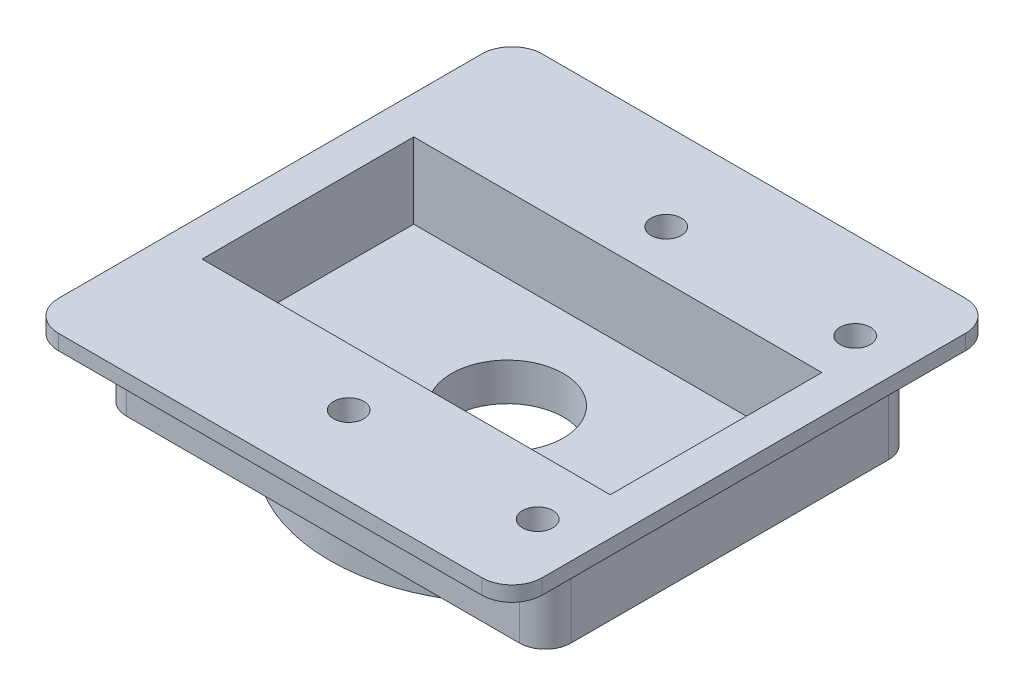
from build123d import *

# Parameters (mm, degrees)
SKETCH_1_W          = 32
SKETCH_1_H          = 32
EXTRUDE_1_DEPTH     = 1
EXTRUDE_2_DEPTH     = 5
SKETCH_2_W          = 27
SKETCH_2_H          = 14
CUT_EXTRUDE_1_DEPTH = 5
SKETCH_4_R          = 11.747624997
EXTRUDE_3_DEPTH     = 2
SKETCH_5_R          = 4.75
CUT_EXTRUDE_2_DEPTH = 0.5
CUT_EXTRUDE_2_TAPER = 37
SKETCH_6_R          = 3.7
CUT_EXTRUDE_3_DEPTH = 8.5
FILLET_1_R          = 2
SKETCH_7_R          = 1
CUT_EXTRUDE_4_DEPTH = 4
CUT_EXTRUDE_4_TAPER = 2


with BuildPart() as part:
    # 草图1 → 凸台-拉伸1 (new body)
    with BuildSketch(Plane(origin=(0, 0, 0), x_dir=(1, 0, 0), z_dir=(0, 1, 0))):
        with Locations((-24.552631543, -18.455578089)):
            Rectangle(SKETCH_1_W, SKETCH_1_H)
    extrude(amount=EXTRUDE_1_DEPTH)

    # 草图3 → 凸台-拉伸2 (add)
    with BuildSketch(Plane.XZ):
        with BuildLine():
            Line((-9.852631543, 8.255578089), (-9.852631543, 29.255578089))
            ThreePointArc((-9.852631543, 29.255578089), (-10.350550015, 30.457659617), (-11.552631543, 30.955578089))
            Line((-11.552631543, 30.955578089), (-37.552631543, 30.955578089))
            ThreePointArc((-37.552631543, 30.955578089), (-38.754713071, 30.457659617), (-39.252631543, 29.255578089))
            Line((-39.252631543, 29.255578089), (-39.252631543, 8.255578089))
            ThreePointArc((-39.252631543, 8.255578089), (-38.754713071, 7.053496561), (-37.552631543, 6.555578089))
            Line((-37.552631543, 6.555578089), (-11.552631543, 6.555578089))
            ThreePointArc((-11.552631543, 6.555578089), (-10.350550015, 7.053496561), (-9.852631543, 8.255578089))
        make_face()
    extrude(amount=EXTRUDE_2_DEPTH)

    # 草图2 → 切除-拉伸1 (cut)
    with BuildSketch(Plane(origin=(0, 1, 0), x_dir=(1, 0, 0), z_dir=(0, 1, 0))):
        with Locations((-24.552631543, -18.455578089)):
            Rectangle(SKETCH_2_W, SKETCH_2_H)
    extrude(amount=-CUT_EXTRUDE_1_DEPTH, mode=Mode.SUBTRACT)

    # 草图4 → 凸台-拉伸3 (add)
    with BuildSketch(Plane.XZ.offset(5)):
        with Locations((-24.552631543, 18.755578089)):
            Circle(SKETCH_4_R)
    extrude(amount=EXTRUDE_3_DEPTH)

    # 草图5 → 切除-拉伸2 (cut)
    with BuildSketch(Plane.XZ.offset(7)):
        with Locations((-24.552631543, 18.755578089)):
            Circle(SKETCH_5_R)
    extrude(amount=-CUT_EXTRUDE_2_DEPTH, taper=CUT_EXTRUDE_2_TAPER, mode=Mode.SUBTRACT)

    # 草图6 → 切除-拉伸3 (cut, through all)
    with BuildSketch(Plane.XZ.offset(6.5)):
        with Locations((-24.552631543, 18.755578089)):
            Circle(SKETCH_6_R)
    extrude(amount=-CUT_EXTRUDE_3_DEPTH, mode=Mode.SUBTRACT)

    # 圆角1
    fillet_1_edges = [part.edges().sort_by_distance(p)[0] for p in [
        (-40.552631543, 0.5, 2.455578089),
        (-8.552631543, 0.5, 2.455578089),
        (-8.552631543, 0.5, 34.455578089),
        (-40.552631543, 0.5, 34.455578089),
    ]]
    fillet(fillet_1_edges, radius=FILLET_1_R)

    # 草图7 → 切除-拉伸4 (cut)
    with BuildSketch(Plane(origin=(0, 1, 0), x_dir=(1, 0, 0), z_dir=(0, 1, 0))):
        with Locations((-24.552631543, -8.255578089)):
            Circle(SKETCH_7_R)
        with Locations((-12.052631543, -8.255578089)):
            Circle(SKETCH_7_R)
        with Locations((-24.552631543, -29.255578089)):
            Circle(SKETCH_7_R)
        with Locations((-12.052631543, -29.255578089)):
            Circle(SKETCH_7_R)
    extrude(amount=-CUT_EXTRUDE_4_DEPTH, taper=CUT_EXTRUDE_4_TAPER, mode=Mode.SUBTRACT)


solid = part.part
